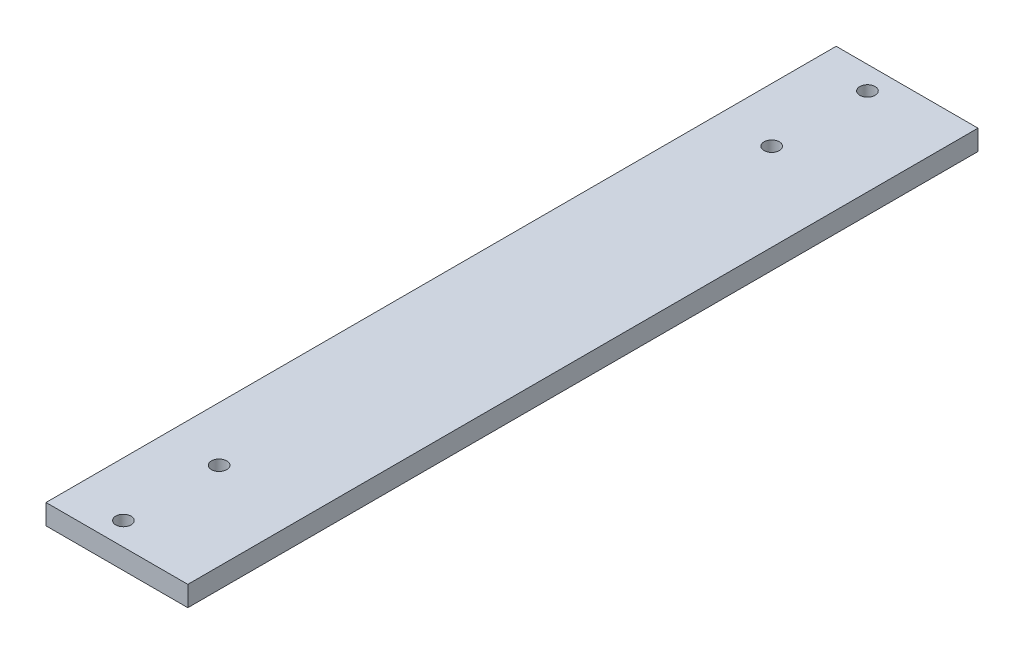
from build123d import *

# Parameters (mm, degrees)
SKETCH1_W            = 44.45
SKETCH1_H            = 247.65
BOSS_EXTRUDE1_DEPTH  = 6.35
M4_CLEARANCE_HOLE1_D = 4.8


with BuildPart() as part:
    # Sketch1 → Boss-Extrude1 (new body)
    with BuildSketch(Plane(origin=(0, 0, 0), x_dir=(1, 0, 0), z_dir=(0, 1, 0))):
        Rectangle(SKETCH1_W, SKETCH1_H)
    extrude(amount=BOSS_EXTRUDE1_DEPTH)

    # M4 Clearance Hole1 (through all)
    with Locations(Plane(origin=(0, 0, 0), x_dir=(-1, 0, 0), z_dir=(0, -1, 0))):
        with Locations((37.2, -116.6), (5.2, -116.6), (5.2, -86.6), (37.2, -86.6), (37.2, 86.6), (37.2, 116.6), (5.2, 116.6), (5.2, 86.6)):
            Hole(M4_CLEARANCE_HOLE1_D / 2)


solid = part.part
